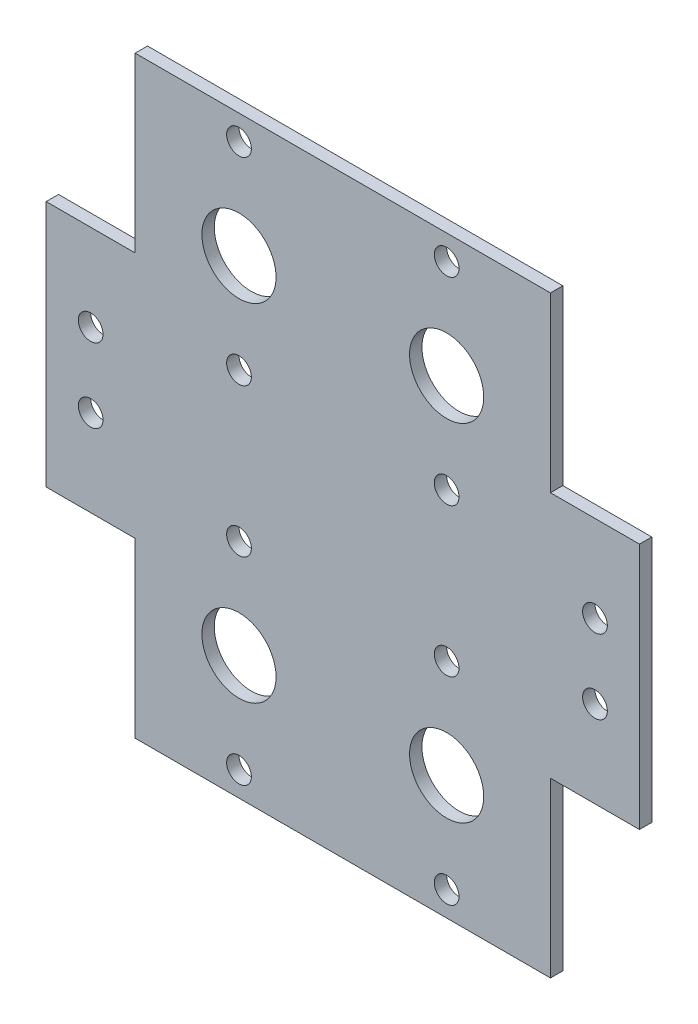
from build123d import *

# Parameters (mm, degrees)
SKETCH1_W           = 240
SKETCH1_H           = 100
BOSS_EXTRUDE1_DEPTH = 5
SKETCH2_W           = 168
SKETCH2_H           = 240
BOSS_EXTRUDE2_DEPTH = 5
SKETCH3_R           = 5
CUT_EXTRUDE1_DEPTH  = 5
SKETCH4_R           = 15
SKETCH4_R_2         = 5
CUT_EXTRUDE2_DEPTH  = 5


with BuildPart() as part:
    # Sketch1 → Boss-Extrude1 (new body)
    with BuildSketch(Plane.XY):
        Rectangle(SKETCH1_W, SKETCH1_H)
    extrude(amount=BOSS_EXTRUDE1_DEPTH)

    # Sketch2 → Boss-Extrude2 (add)
    with BuildSketch(Plane.XY.offset(5)):
        Rectangle(SKETCH2_W, SKETCH2_H)
    extrude(amount=-BOSS_EXTRUDE2_DEPTH)

    # Sketch3 → Cut-Extrude1 (cut)
    with BuildSketch(Plane.XY.offset(5)):
        with Locations((-102, 15)):
            Circle(SKETCH3_R)
        with Locations((102, 15)):
            Circle(SKETCH3_R)
        with Locations((102, -15)):
            Circle(SKETCH3_R)
        with Locations((-102, -15)):
            Circle(SKETCH3_R)
    extrude(amount=-CUT_EXTRUDE1_DEPTH, mode=Mode.SUBTRACT)

    # Sketch4 → Cut-Extrude2 (cut)
    with BuildSketch(Plane.XY.offset(5)):
        with Locations((-42, -70)):
            Circle(SKETCH4_R)
        with Locations((42, -70)):
            Circle(SKETCH4_R)
        with Locations((-42, -30)):
            Circle(SKETCH4_R_2)
        with Locations((-42, -110)):
            Circle(SKETCH4_R_2)
        with Locations((42, -110)):
            Circle(SKETCH4_R_2)
        with Locations((42, -30)):
            Circle(SKETCH4_R_2)
        with Locations((42, 30)):
            Circle(SKETCH4_R_2)
        with Locations((42, 110)):
            Circle(SKETCH4_R_2)
        with Locations((-42, 110)):
            Circle(SKETCH4_R_2)
        with Locations((-42, 30)):
            Circle(SKETCH4_R_2)
        with Locations((42, 70)):
            Circle(SKETCH4_R)
        with Locations((-42, 70)):
            Circle(SKETCH4_R)
    extrude(amount=-CUT_EXTRUDE2_DEPTH, mode=Mode.SUBTRACT)


solid = part.part
